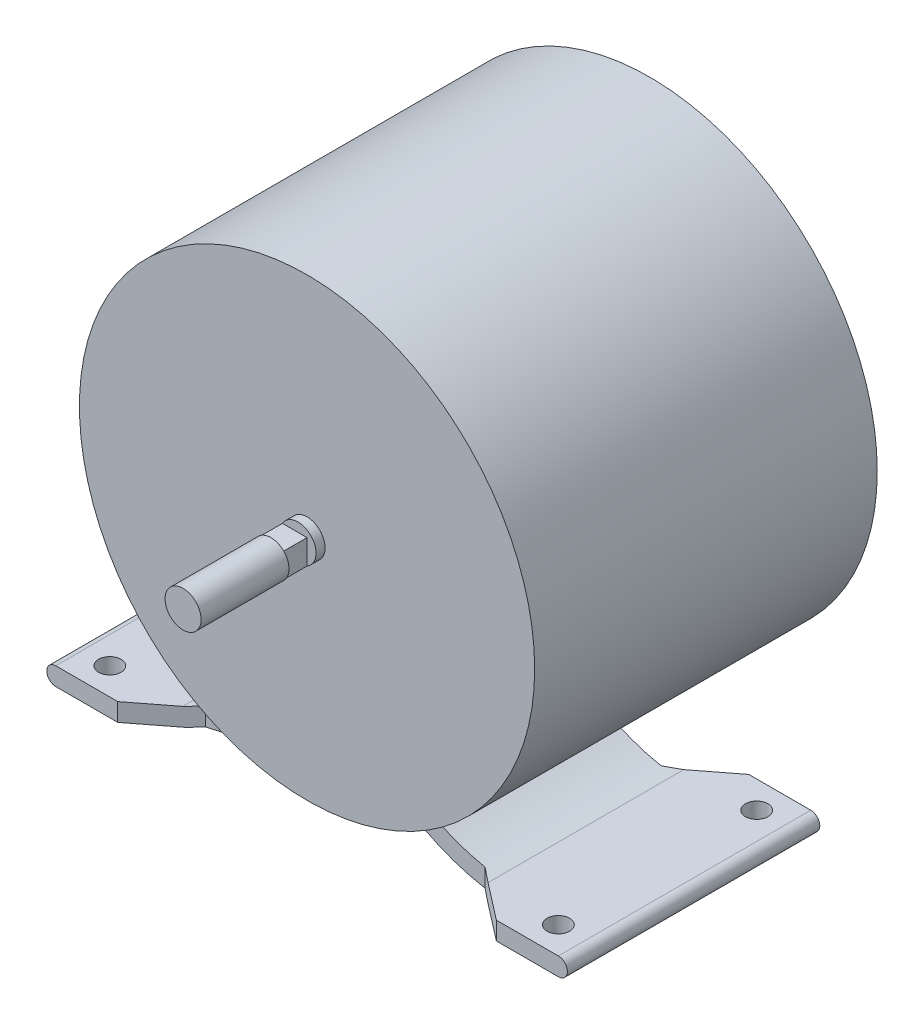
from build123d import *

# Parameters (mm, degrees)
SKETCH1_R           = 50.5
BOSS_EXTRUDE1_DEPTH = 76
SKETCH2_R           = 4
BOSS_EXTRUDE2_DEPTH = 27.5
SKETCH3_R           = 15.5
BOSS_EXTRUDE3_DEPTH = 56
CUT_EXTRUDE1_DEPTH  = 14
SKETCH6_R           = 50.5
BOSS_EXTRUDE4_DEPTH = 69
CUT_EXTRUDE2_REACH  = 109
SKETCH7_R           = 2.5
CUT_EXTRUDE3_START  = -229.584638372
SKETCH8_W           = 6
SKETCH8_H           = 2
CUT_EXTRUDE3_DEPTH  = 230.584638372
CIRPATTERN1_COUNT   = 2
CIRPATTERN1_ANGLE   = 90


with BuildPart() as part:
    # Sketch1 → Boss-Extrude1 (new body)
    with BuildSketch(Plane.XY):
        Circle(SKETCH1_R)
    extrude(amount=-BOSS_EXTRUDE1_DEPTH)

    # Sketch2 → Boss-Extrude2 (add)
    with BuildSketch(Plane.XY):
        Circle(SKETCH2_R)
    extrude(amount=BOSS_EXTRUDE2_DEPTH)

    # Sketch3 → section 1 of loft1
    with BuildSketch(Plane(origin=(0, 0, -82), x_dir=(-1, 0, 0), z_dir=(0, 0, -1)), mode=Mode.PRIVATE) as loft1_s1:
        Circle(SKETCH3_R)
    # loft from a face of the part (loft1)
    loft([part.faces().sort_by_distance((0, 0, -76))[0], loft1_s1.sketch])

    # Sketch4 → Boss-Extrude3 (add)
    with BuildSketch(Plane.XY):
        with BuildLine():
            Line((-55.75, -52.5), (-33.867548492, -52.5))
            ThreePointArc((-33.867548492, -52.5), (-25.666216724, -50.654640627), (-18.012227442, -47.178487286))
            ThreePointArc((-18.012227442, -47.178487286), (0, -50.5), (18.012227442, -47.178487286))
            ThreePointArc((18.012227442, -47.178487286), (25.666216724, -50.654640627), (33.867548492, -52.5))
            Line((33.867548492, -52.5), (55.75, -52.5))
            ThreePointArc((55.75, -52.5), (57.75, -54.5), (55.75, -56.5))
            Line((55.75, -56.5), (33.635158839, -56.5))
            ThreePointArc((33.635158839, -56.5), (25.41686368, -54.776707383), (17.660730448, -51.559175711))
            ThreePointArc((17.660730448, -51.559175711), (0, -54.5), (-17.660730448, -51.559175711))
            ThreePointArc((-17.660730448, -51.559175711), (-25.41686368, -54.776707383), (-33.635158839, -56.5))
            Line((-33.635158839, -56.5), (-55.75, -56.5))
            ThreePointArc((-55.75, -56.5), (-57.75, -54.5), (-55.75, -52.5))
        make_face()
    extrude(amount=-BOSS_EXTRUDE3_DEPTH)

    # Sketch5 → Cut-Extrude1 (cut)
    with BuildSketch(Plane.XZ.offset(56.5)):
        Polygon((-31, -8.5), (31, -8.5), (42, 0), (-42, 0), align=None)
        Polygon((-42, -56), (-31, -47.5), (31, -47.5), (42, -56), align=None)
    extrude(amount=-CUT_EXTRUDE1_DEPTH, mode=Mode.SUBTRACT)

    # Sketch6 → Boss-Extrude4 (add)
    with BuildSketch(Plane.XY):
        Circle(SKETCH6_R)
    extrude(amount=-BOSS_EXTRUDE4_DEPTH)

    # Sketch7 → Cut-Extrude2 (cut, up to next)
    with BuildSketch(Plane.XZ.offset(56.5), mode=Mode.PRIVATE) as cut_extrude2_sk1:
        with Locations((-49.75, -6)):
            Circle(SKETCH7_R)
    cut_extrude2_tool1 = extrude(cut_extrude2_sk1.sketch, amount=-CUT_EXTRUDE2_REACH, mode=Mode.PRIVATE) & part.part
    add(cut_extrude2_tool1.solids().sort_by_distance((-49.75, -56.5, -6))[0], mode=Mode.SUBTRACT)
    # Sketch7 → Cut-Extrude2 (cut, up to next)
    with BuildSketch(Plane.XZ.offset(56.5), mode=Mode.PRIVATE) as cut_extrude2_sk2:
        with Locations((-49.75, -50)):
            Circle(SKETCH7_R)
    cut_extrude2_tool2 = extrude(cut_extrude2_sk2.sketch, amount=-CUT_EXTRUDE2_REACH, mode=Mode.PRIVATE) & part.part
    add(cut_extrude2_tool2.solids().sort_by_distance((-49.75, -56.5, -50))[0], mode=Mode.SUBTRACT)
    # Sketch7 → Cut-Extrude2 (cut, up to next)
    with BuildSketch(Plane.XZ.offset(56.5), mode=Mode.PRIVATE) as cut_extrude2_sk3:
        with Locations((49.75, -50)):
            Circle(SKETCH7_R)
    cut_extrude2_tool3 = extrude(cut_extrude2_sk3.sketch, amount=-CUT_EXTRUDE2_REACH, mode=Mode.PRIVATE) & part.part
    add(cut_extrude2_tool3.solids().sort_by_distance((49.75, -56.5, -50))[0], mode=Mode.SUBTRACT)
    # Sketch7 → Cut-Extrude2 (cut, up to next)
    with BuildSketch(Plane.XZ.offset(56.5), mode=Mode.PRIVATE) as cut_extrude2_sk4:
        with Locations((49.75, -6)):
            Circle(SKETCH7_R)
    cut_extrude2_tool4 = extrude(cut_extrude2_sk4.sketch, amount=-CUT_EXTRUDE2_REACH, mode=Mode.PRIVATE) & part.part
    add(cut_extrude2_tool4.solids().sort_by_distance((49.75, -56.5, -6))[0], mode=Mode.SUBTRACT)

    # Sketch8 → Cut-Extrude3 (cut)
    with BuildSketch(Plane(origin=(170.834638372, -107.162802213, -173.5), x_dir=(0, 0, -1), z_dir=(1, 0, 0)).offset(CUT_EXTRUDE3_START)):
        with Locations((-178.5, 110.162802213)):
            Rectangle(SKETCH8_W, SKETCH8_H)
    cut_extrude3 = extrude(amount=CUT_EXTRUDE3_DEPTH, mode=Mode.SUBTRACT)

    # CirPattern1: Cut-Extrude3 ×2 about axis
    cirpattern1_axis = Axis((0, 0, 27.5), (0, 0, -1))
    for i in range(1, CIRPATTERN1_COUNT):
        add(cut_extrude3.rotate(cirpattern1_axis, i * CIRPATTERN1_ANGLE / (CIRPATTERN1_COUNT - 1)), mode=Mode.SUBTRACT)


solid = part.part
